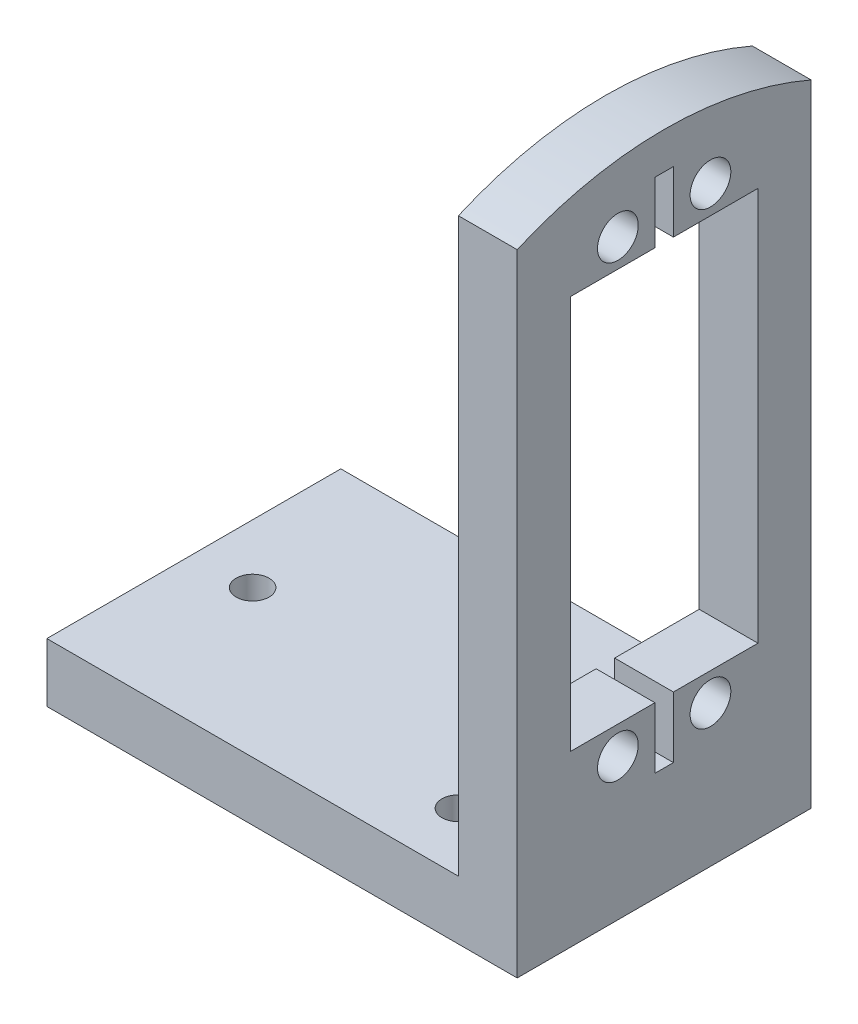
from build123d import *

# Parameters (mm, degrees)
SKETCH3_W           = 31.75
SKETCH3_H           = 67.207500078
SKETCH3_R           = 2.200000045
BOSS_EXTRUDE1_DEPTH = 6.35
SKETCH5_W           = 31.75
SKETCH5_H           = 6.35
BOSS_EXTRUDE2_DEPTH = 50.8
SKETCH6_R           = 1.777000002
CUT_EXTRUDE1_DEPTH  = 7.35
CUT_EXTRUDE2_DEPTH  = 51.8


with BuildPart() as part:
    # Sketch3 → Boss-Extrude1 (new body)
    with BuildSketch(Plane(origin=(0, 0, 0), x_dir=(0, 0, -1), z_dir=(1, 0, 0))):
        with Locations((15.875, 33.603750039)):
            Rectangle(SKETCH3_W, SKETCH3_H)
        with Locations((10.874999967, 8.935000037)):
            Circle(SKETCH3_R, mode=Mode.SUBTRACT)
        with Locations((20.875000033, 8.935000037)):
            Circle(SKETCH3_R, mode=Mode.SUBTRACT)
        with Locations((10.874999967, 57.535000119)):
            Circle(SKETCH3_R, mode=Mode.SUBTRACT)
        with Locations((20.875000033, 57.535000119)):
            Circle(SKETCH3_R, mode=Mode.SUBTRACT)
        Polygon((5.748000061, 54.507500078), (14.875, 54.507500078), (14.875, 61.111500078), (16.875, 61.111500078), (16.875, 54.507500078), (26.001999939, 54.507500078), (26.001999939, 11.962500078), (16.875, 11.962500078), (16.875, 5.358500078), (14.875, 5.358500078), (14.875, 11.962500078), (5.748000061, 11.962500078), align=None, mode=Mode.SUBTRACT)
    extrude(amount=BOSS_EXTRUDE1_DEPTH)

    # Sketch5 → Boss-Extrude2 (add)
    with BuildSketch(Plane(origin=(6.35, 0, 0), x_dir=(0, 0, -1), z_dir=(1, 0, 0))):
        with Locations((15.875, -3.175)):
            Rectangle(SKETCH5_W, SKETCH5_H)
    extrude(amount=-BOSS_EXTRUDE2_DEPTH)

    # Sketch6 → Cut-Extrude1 (cut, through all)
    with BuildSketch(Plane(origin=(0, 0, 0), x_dir=(1, 0, 0), z_dir=(0, 1, 0))):
        with Locations((-6.35, 6.35)):
            Circle(SKETCH6_R)
        with Locations((-38.1, 15.875)):
            Circle(SKETCH6_R)
        with Locations((-6.35, 25.4)):
            Circle(SKETCH6_R)
    extrude(amount=-CUT_EXTRUDE1_DEPTH, mode=Mode.SUBTRACT)

    # Sketch7 → Cut-Extrude2 (cut, through all)
    with BuildSketch(Plane(origin=(6.35, 0, 0), x_dir=(0, 0, -1), z_dir=(1, 0, 0))):
        with BuildLine():
            Line((0, 61.774194579), (0, 82.748877538))
            Line((0, 82.748877538), (31.75, 82.748877538))
            Line((31.75, 82.748877538), (31.75, 61.774194579))
            ThreePointArc((31.75, 61.774194579), (15.875, 65.0875), (0, 61.774194579))
        make_face()
    extrude(amount=-CUT_EXTRUDE2_DEPTH, mode=Mode.SUBTRACT)


solid = part.part
